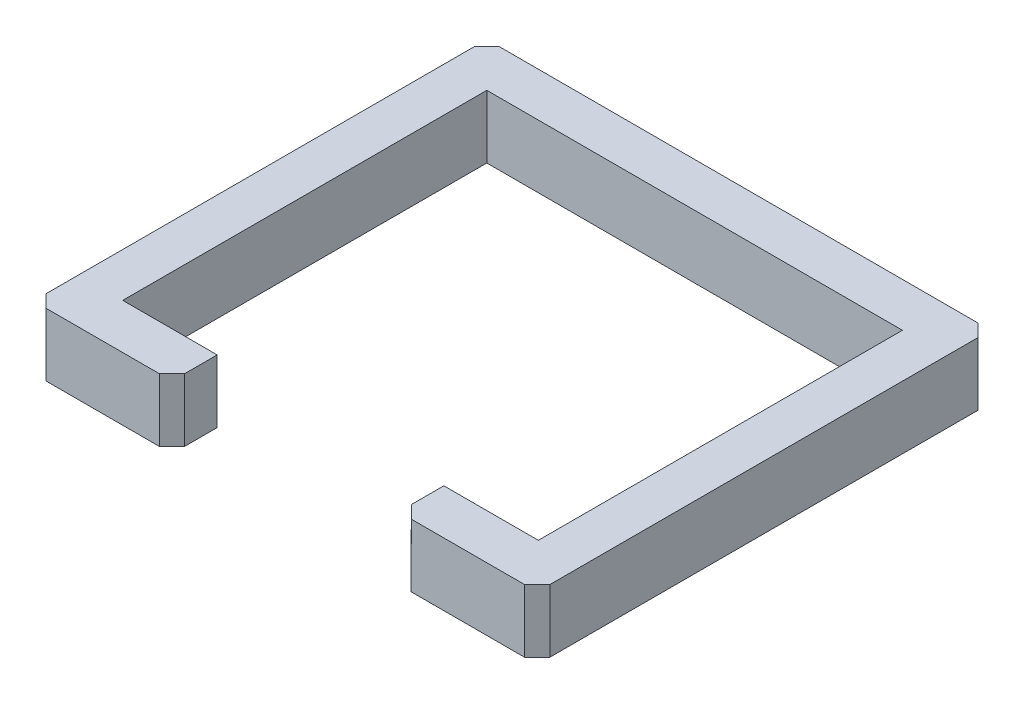
from build123d import *

# Parameters (mm, degrees)
BOSS_EXTRUDE1_DEPTH = 63.5


with BuildPart() as part:
    # Sketch1 → Boss-Extrude1 (new body, symmetric)
    with BuildSketch(Plane(origin=(0, 57.843753362, -2.3797e-05), x_dir=(-1, 0, 0), z_dir=(0, -0.99999992, 0.0003994))):
        Polygon((-412.265833354, -477.954450626), (-183.665833354, -477.954450626), (-158.265833354, -452.554448601), (-158.265833354, -386.787080658), (-348.765833354, -386.787080658), (-348.765833354, 347.545615216), (489.434166646, 347.545615216), (489.434166646, -386.787080658), (298.934166646, -386.787080658), (298.934166646, -452.554448601), (324.334166646, -477.954450626), (552.934166646, -477.954450626), (578.334166646, -452.554448601), (578.334166646, 411.04562028), (552.934166646, 436.445622306), (-412.265833354, 436.445622306), (-437.665833354, 411.04562028), (-437.665833354, -452.554448601), align=None)
    extrude(amount=BOSS_EXTRUDE1_DEPTH, both=True)


solid = part.part
